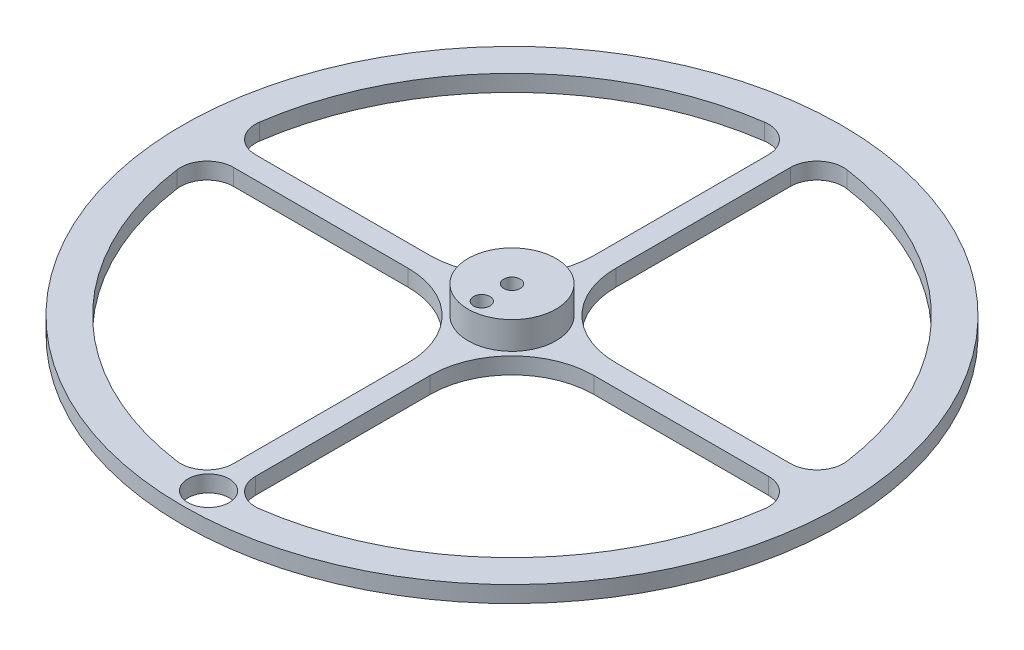
from build123d import *

# Parameters (mm, degrees)
SKETCH1_R           = 60
SKETCH1_R_2         = 54
SKETCH1_R_3         = 8
BOSS_EXTRUDE1_DEPTH = 3
SKETCH1_3_R         = 8
BOSS_EXTRUDE2_DEPTH = 5
CUT_EXTRUDE1_REACH  = 10
SKETCH2_R           = 1.5
CUT_EXTRUDE2_REACH  = 5
SKETCH3_R           = 3.75
SKETCH4_R           = 1.5
CUT_EXTRUDE3_DEPTH  = 5


with BuildPart() as part:
    # Sketch1 → Boss-Extrude1 (new body)
    with BuildSketch(Plane(origin=(0, 0, 0), x_dir=(1, 0, 0), z_dir=(0, 1, 0))):
        Circle(SKETCH1_R)
        Circle(SKETCH1_R_2, mode=Mode.SUBTRACT)
        with BuildLine():
            ThreePointArc((7.5, -53.47663041), (3.660460389, -52.338407931), (2.000000204, -48.694167705))
            Line((2.000000204, -48.694167705), (2.000000204, -16.899494443))
            ThreePointArc((2.000000204, -16.899494443), (3.134156671, -11.197704847), (6.363961031, -6.363961031))
            ThreePointArc((6.363961031, -6.363961031), (11.197704847, -3.134156671), (16.899494443, -2.000000204))
            Line((16.899494443, -2.000000204), (48.694167705, -2.000000204))
            ThreePointArc((48.694167705, -2.000000204), (52.338407931, -3.660460389), (53.47663041, -7.5))
            ThreePointArc((53.47663041, -7.5), (53.868998701, -3.759119436), (54, 0))
            ThreePointArc((54, 0), (53.868998701, 3.759119436), (53.47663041, 7.5))
            ThreePointArc((53.47663041, 7.5), (52.338407931, 3.660460389), (48.694167705, 2.000000204))
            Line((48.694167705, 2.000000204), (16.899494443, 2.000000204))
            ThreePointArc((16.899494443, 2.000000204), (11.197704847, 3.134156671), (6.363961031, 6.363961031))
            ThreePointArc((6.363961031, 6.363961031), (3.134156671, 11.197704847), (2.000000204, 16.899494443))
            Line((2.000000204, 16.899494443), (2.000000204, 48.694167705))
            ThreePointArc((2.000000204, 48.694167705), (3.660460389, 52.338407931), (7.5, 53.47663041))
            ThreePointArc((7.5, 53.47663041), (0, 54), (-7.5, 53.47663041))
            ThreePointArc((-7.5, 53.47663041), (-3.660460389, 52.338407931), (-2.000000204, 48.694167705))
            Line((-2.000000204, 48.694167705), (-2.000000204, 16.899494443))
            ThreePointArc((-2.000000204, 16.899494443), (-3.134156671, 11.197704847), (-6.363961031, 6.363961031))
            ThreePointArc((-6.363961031, 6.363961031), (-11.197704847, 3.134156671), (-16.899494443, 2.000000204))
            Line((-16.899494443, 2.000000204), (-48.694167705, 2.000000204))
            ThreePointArc((-48.694167705, 2.000000204), (-52.338407931, 3.660460389), (-53.47663041, 7.5))
            ThreePointArc((-53.47663041, 7.5), (-54, 0), (-53.47663041, -7.5))
            ThreePointArc((-53.47663041, -7.5), (-52.338407931, -3.660460389), (-48.694167705, -2.000000204))
            Line((-48.694167705, -2.000000204), (-16.899494443, -2.000000204))
            ThreePointArc((-16.899494443, -2.000000204), (-11.197704847, -3.134156671), (-6.363961031, -6.363961031))
            ThreePointArc((-6.363961031, -6.363961031), (-3.134156671, -11.197704847), (-2.000000204, -16.899494443))
            Line((-2.000000204, -16.899494443), (-2.000000204, -48.694167705))
            ThreePointArc((-2.000000204, -48.694167705), (-3.660460389, -52.338407931), (-7.5, -53.47663041))
            ThreePointArc((-7.5, -53.47663041), (0, -54), (7.5, -53.47663041))
        make_face()
        Circle(SKETCH1_R_3, mode=Mode.SUBTRACT)
        Circle(SKETCH1_R_3)
    extrude(amount=-BOSS_EXTRUDE1_DEPTH)

    # Sketch1_3 → Boss-Extrude2 (add)
    with BuildSketch(Plane(origin=(0, 0, 0), x_dir=(1, 0, 0), z_dir=(0, 1, 0))):
        Circle(SKETCH1_3_R)
    extrude(amount=BOSS_EXTRUDE2_DEPTH)

    # Sketch2 → Cut-Extrude1 (cut, up to next)
    with BuildSketch(Plane(origin=(0, 5, 0), x_dir=(1, 0, 0), z_dir=(0, 1, 0)), mode=Mode.PRIVATE) as cut_extrude1_sk1:
        Circle(SKETCH2_R)
    cut_extrude1_tool1 = extrude(cut_extrude1_sk1.sketch, amount=-CUT_EXTRUDE1_REACH, mode=Mode.PRIVATE) & part.part
    add(cut_extrude1_tool1.solids().sort_by_distance((0, 5, 0))[0], mode=Mode.SUBTRACT)

    # Sketch3 → Cut-Extrude2 (cut, up to next)
    with BuildSketch(Plane(origin=(0, 0, 0), x_dir=(1, 0, 0), z_dir=(0, 1, 0)), mode=Mode.PRIVATE) as cut_extrude2_sk1:
        with Locations((0, -55.25)):
            Circle(SKETCH3_R)
    cut_extrude2_tool1 = extrude(cut_extrude2_sk1.sketch, amount=-CUT_EXTRUDE2_REACH, mode=Mode.PRIVATE) & part.part
    add(cut_extrude2_tool1.solids().sort_by_distance((0, 0, 55.25))[0], mode=Mode.SUBTRACT)

    # Sketch4 → Cut-Extrude3 (cut)
    with BuildSketch(Plane(origin=(0, 5, 0), x_dir=(1, 0, 0), z_dir=(0, 1, 0))):
        with Locations((0, -5.5)):
            Circle(SKETCH4_R)
    extrude(amount=-CUT_EXTRUDE3_DEPTH, mode=Mode.SUBTRACT)


solid = part.part
